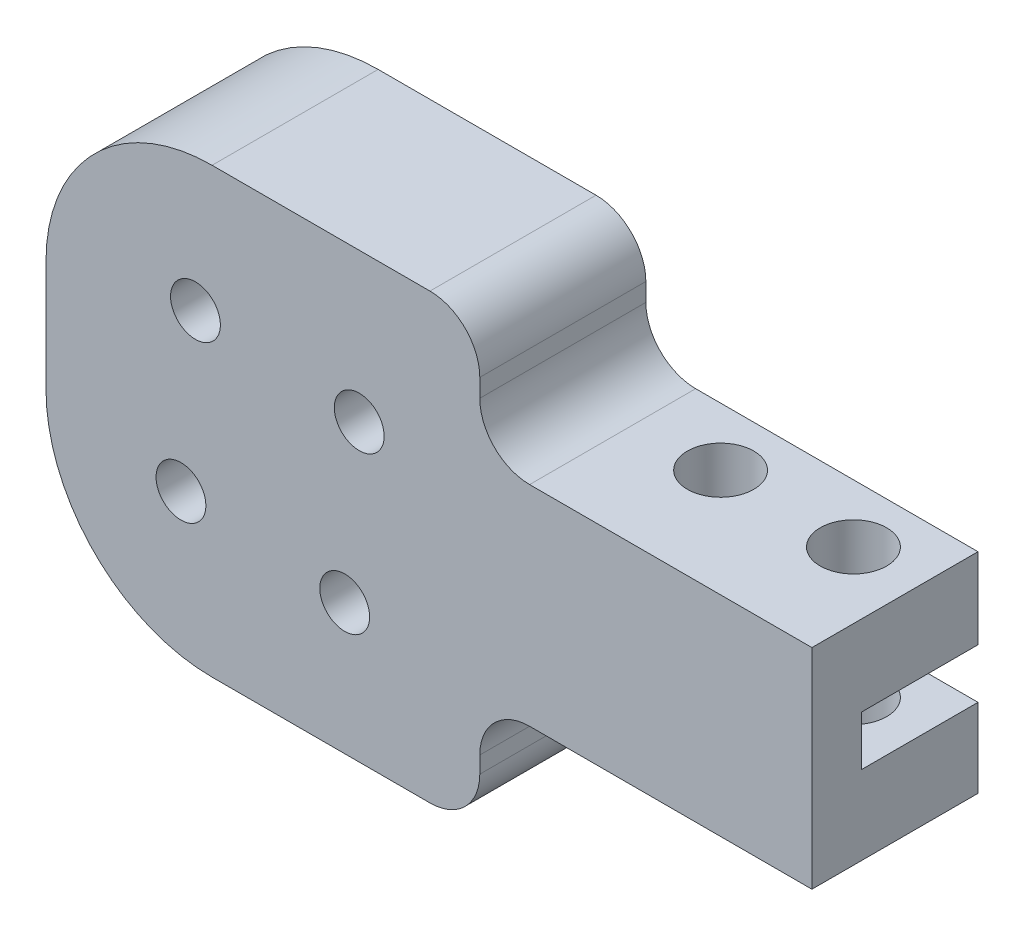
from build123d import *

# Parameters (mm, degrees)
ESQUISSE1_R                  = 50
BOSS_EXTRU_1_DEPTH           = 10
ESQUISSE2_R                  = 10
ENL_V_MAT_EXTRU_1_DEPTH      = 7
ESQUISSE4_W                  = 52.254082237
ESQUISSE4_H                  = 3
ENL_V_MAT_EXTRU_2_DEPTH      = 7
ESQUISSE6_W                  = 109.070687356
ESQUISSE6_H                  = 40.053485354
ENL_V_MAT_EXTRU_3_DEPTH      = 10
ESQUISSE8_W                  = 43.455454537
ESQUISSE8_H                  = 73.019440826
ENL_V_MAT_EXTRU_4_DEPTH      = 10
ESQUISSE9_W                  = 83.209839814
ESQUISSE9_H                  = 41.336413251
ENL_V_MAT_EXTRU_5_DEPTH      = 10
ESQUISSE10_W                 = 31.997575123
ESQUISSE10_H                 = 50.623415865
ENL_V_MAT_EXTRU_6_DEPTH      = 10
ESQUISSE11_R                 = 1.5
ENL_V_MAT_EXTRU_7_DEPTH      = 10
CONG_1_R                     = 10
ESQUISSE16_W                 = 20
ESQUISSE16_H                 = 7
ENL_V_MAT_EXTRU_11_DEPTH     = 10
CONG_2_R                     = 3
R_P_TITION_CIRCULAIRE1_COUNT = 4
ESQUISSE17_W                 = 20
ESQUISSE17_H                 = 7.090454939
ENL_V_MAT_EXTRU_12_DEPTH     = 10
CONG_3_R                     = 3
ESQUISSE19_R                 = 2
ENL_V_MAT_EXTRU_13_DEPTH     = 20
ESQUISSE19_3_R               = 2
ENL_V_MAT_EXTRU_14_DEPTH     = 20


with BuildPart() as part:
    # Esquisse1 → Boss.-Extru.1 (new body)
    with BuildSketch(Plane.XY):
        with Locations((-18.393953774, 17.863079719)):
            Circle(ESQUISSE1_R)
    extrude(amount=BOSS_EXTRU_1_DEPTH)

    # Esquisse2 → Enl_v. mat.-Extru.1 (cut)
    with BuildSketch(Plane(origin=(0, 0, 0), x_dir=(-1, 0, 0), z_dir=(0, 0, -1))):
        with Locations((18.393953774, 17.863079719)):
            Circle(ESQUISSE2_R)
    extrude(amount=-ENL_V_MAT_EXTRU_1_DEPTH, mode=Mode.SUBTRACT)

    # Esquisse4 → Enl_v. mat.-Extru.2 (cut)
    with BuildSketch(Plane(origin=(0, 0, 0), x_dir=(-1, 0, 0), z_dir=(0, 0, -1))):
        with Locations((-12.461439017, 17.863079719)):
            Rectangle(ESQUISSE4_W, ESQUISSE4_H)
    extrude(amount=-ENL_V_MAT_EXTRU_2_DEPTH, mode=Mode.SUBTRACT)

    # Esquisse6 → Enl_v. mat.-Extru.3 (cut)
    with BuildSketch(Plane(origin=(0, 0, 0), x_dir=(-1, 0, 0), z_dir=(0, 0, -1))):
        with Locations((22.721030159, 51.335342826)):
            Rectangle(ESQUISSE6_W, ESQUISSE6_H)
    extrude(amount=-ENL_V_MAT_EXTRU_3_DEPTH, mode=Mode.SUBTRACT)

    # Esquisse8 → Enl_v. mat.-Extru.4 (cut)
    with BuildSketch(Plane(origin=(0, 0, 0), x_dir=(-1, 0, 0), z_dir=(0, 0, -1))):
        with Locations((53.615379414, 4.486243449)):
            Rectangle(ESQUISSE8_W, ESQUISSE8_H)
    extrude(amount=-ENL_V_MAT_EXTRU_4_DEPTH, mode=Mode.SUBTRACT)

    # Esquisse9 → Enl_v. mat.-Extru.5 (cut)
    with BuildSketch(Plane(origin=(0, 0, 0), x_dir=(-1, 0, 0), z_dir=(0, 0, -1))):
        with Locations((0.000153838, -16.052922386)):
            Rectangle(ESQUISSE9_W, ESQUISSE9_H)
    extrude(amount=-ENL_V_MAT_EXTRU_5_DEPTH, mode=Mode.SUBTRACT)

    # Esquisse10 → Enl_v. mat.-Extru.6 (cut)
    with BuildSketch(Plane(origin=(0, 0, 0), x_dir=(-1, 0, 0), z_dir=(0, 0, -1))):
        with Locations((-30.231359533, 14.74109753)):
            Rectangle(ESQUISSE10_W, ESQUISSE10_H)
    extrude(amount=-ENL_V_MAT_EXTRU_6_DEPTH, mode=Mode.SUBTRACT)

    # Esquisse11 → Enl_v. mat.-Extru.7 (cut)
    with BuildSketch(Plane(origin=(0, 0, 7), x_dir=(-1, 0, 0), z_dir=(0, 0, -1))):
        with Locations((22.887652145, 23.230264731)):
            Circle(ESQUISSE11_R)
    enl_v_mat_extru_7 = extrude(amount=-ENL_V_MAT_EXTRU_7_DEPTH, mode=Mode.SUBTRACT)

    # Cong_1
    cong_1_edges = [part.edges().sort_by_distance(p)[0] for p in [
        (-31.887652145, 31.308600149, 5),
        (-31.887652145, 4.61528424, 5),
    ]]
    fillet(cong_1_edges, radius=CONG_1_R)

    # Esquisse16 → Enl_v. mat.-Extru.11 (cut)
    with BuildSketch(Plane(origin=(0, 0, 0), x_dir=(-1, 0, 0), z_dir=(0, 0, -1))):
        with Locations((-4.232571971, 8.11528424)):
            Rectangle(ESQUISSE16_W, ESQUISSE16_H)
    extrude(amount=-ENL_V_MAT_EXTRU_11_DEPTH, mode=Mode.SUBTRACT)

    # Cong_2
    cong_2_edges = [part.edges().sort_by_distance(p)[0] for p in [
        (-5.767428029, 4.61528424, 5),
        (-5.767428029, 11.61528424, 5),
    ]]
    fillet(cong_2_edges, radius=CONG_2_R)

    # R_p_tition circulaire1: Enl_v. mat.-Extru.7 ×4 about axis
    r_p_tition_circulaire1_axis = Axis((-18.393953774, 17.863079719, 7), (0, 0, -1))
    for i in range(1, R_P_TITION_CIRCULAIRE1_COUNT):
        add(enl_v_mat_extru_7.rotate(r_p_tition_circulaire1_axis, i * 360 / R_P_TITION_CIRCULAIRE1_COUNT), mode=Mode.SUBTRACT)

    # Esquisse17 → Enl_v. mat.-Extru.12 (cut)
    with BuildSketch(Plane(origin=(0, 0, 0), x_dir=(-1, 0, 0), z_dir=(0, 0, -1))):
        with Locations((-4.232571971, 27.76337268)):
            Rectangle(ESQUISSE17_W, ESQUISSE17_H)
    extrude(amount=-ENL_V_MAT_EXTRU_12_DEPTH, mode=Mode.SUBTRACT)

    # Cong_3
    cong_3_edges = [part.edges().sort_by_distance(p)[0] for p in [
        (-5.767428029, 24.21814521, 5),
        (-5.767428029, 31.308600149, 5),
    ]]
    fillet(cong_3_edges, radius=CONG_3_R)

    # Esquisse19 → Enl_v. mat.-Extru.13 (cut)
    with BuildSketch(Plane.XZ.offset(-11.61528424)):
        with Locations((10.232571971, 3.5)):
            Circle(ESQUISSE19_R)
    extrude(amount=-ENL_V_MAT_EXTRU_13_DEPTH, mode=Mode.SUBTRACT)

    # Esquisse19_3 → Enl_v. mat.-Extru.14 (cut)
    with BuildSketch(Plane.XZ.offset(-11.61528424)):
        with Locations((10.232571971, 3.5)):
            Circle(ESQUISSE19_3_R)
        with Locations((2.232571971, 3.5)):
            Circle(ESQUISSE19_3_R)
    extrude(amount=-ENL_V_MAT_EXTRU_14_DEPTH, mode=Mode.SUBTRACT)


solid = part.part
